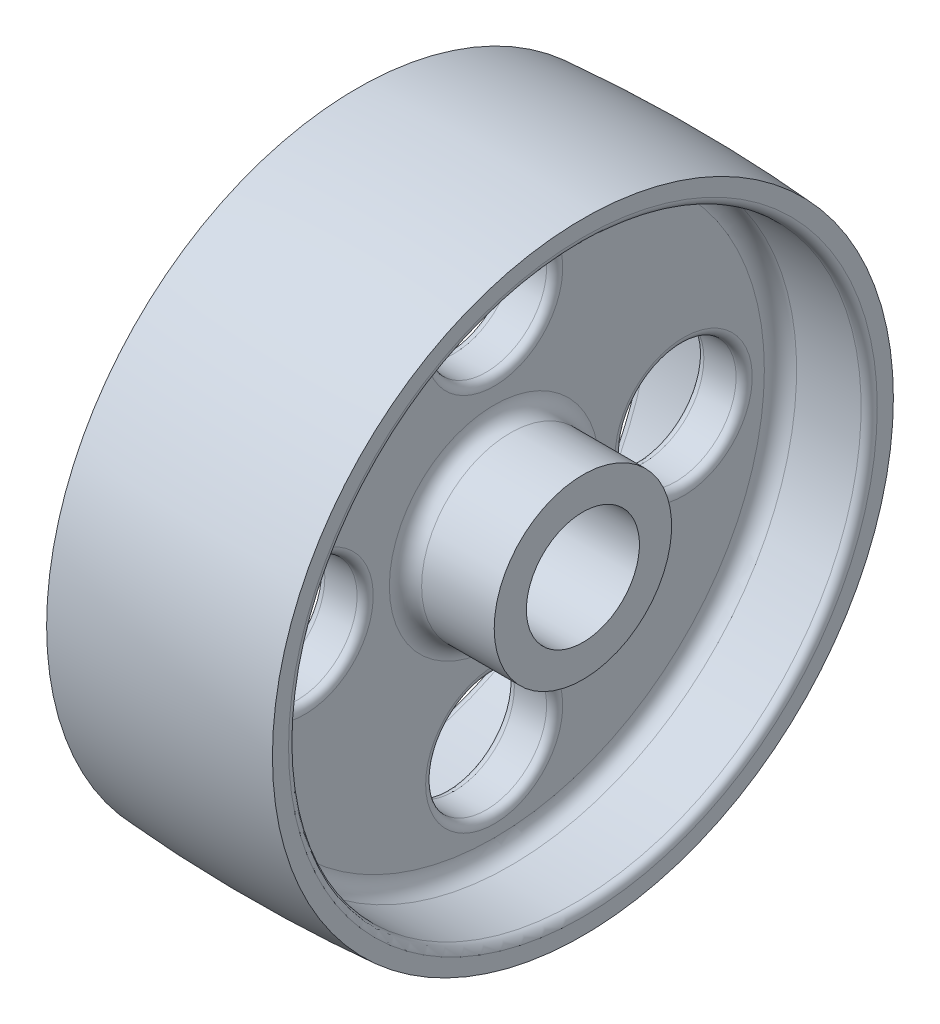
from build123d import *

# Parameters (mm, degrees)
CUT_EXTRUDE2_REACH             = 24.225
SKETCH2_R                      = 11.90625
CUT_EXTRUDE2_DIRECTION_2_REACH = 24.225
FILLET1_R                      = 1.5875


with BuildPart() as part:
    # Sketch1 → Revolve1 (revolve)
    with BuildSketch(Plane.XY):
        with BuildLine():
            Line((22.225, 11.1252), (22.225, 17.4625))
            Line((22.225, 17.4625), (7.9375, 17.4625))
            ThreePointArc((7.9375, 17.4625), (5.69243597, 18.39243597), (4.7625, 20.6375))
            Line((4.7625, 20.6375), (4.7625, 53.18125))
            ThreePointArc((4.7625, 53.18125), (5.69243597, 55.42631403), (7.9375, 56.35625))
            Line((7.9375, 56.35625), (20.6375, 56.35625))
            ThreePointArc((20.6375, 56.35625), (21.760032015, 56.821217985), (22.225, 57.94375))
            Line((22.225, 57.94375), (22.225, 61.11875))
            ThreePointArc((22.225, 61.11875), (0, 61.9125), (-22.225, 61.11875))
            Line((-22.225, 61.11875), (-22.225, 57.94375))
            ThreePointArc((-22.225, 57.94375), (-21.760032015, 56.821217985), (-20.6375, 56.35625))
            Line((-20.6375, 56.35625), (-7.9375, 56.35625))
            ThreePointArc((-7.9375, 56.35625), (-5.69243597, 55.42631403), (-4.7625, 53.18125))
            Line((-4.7625, 53.18125), (-4.7625, 20.6375))
            ThreePointArc((-4.7625, 20.6375), (-5.69243597, 18.39243597), (-7.9375, 17.4625))
            Line((-7.9375, 17.4625), (-22.225, 17.4625))
            Line((-22.225, 17.4625), (-22.225, 11.1252))
            Line((-22.225, 11.1252), (22.225, 11.1252))
        make_face()
    revolve(axis=Axis((0, 0, 0), (1, 0, 0)))

    # Sketch2 → Cut-Extrude2 (cut, up to next)
    with BuildSketch(Plane(origin=(0, 0, 0), x_dir=(0, 0, -1), z_dir=(1, 0, 0)), mode=Mode.PRIVATE) as cut_extrude2_sk1:
        with Locations((0, 37.30625)):
            Circle(SKETCH2_R)
    cut_extrude2_tool1 = extrude(cut_extrude2_sk1.sketch, amount=-CUT_EXTRUDE2_REACH, mode=Mode.PRIVATE) & part.part
    add(cut_extrude2_tool1.solids().sort_by_distance((0, 37.30625, 0))[0], mode=Mode.SUBTRACT)
    # Sketch2 → Cut-Extrude2 (cut, up to next)
    with BuildSketch(Plane(origin=(0, 0, 0), x_dir=(0, 0, -1), z_dir=(1, 0, 0)), mode=Mode.PRIVATE) as cut_extrude2_sk2:
        with Locations((37.30625, 0)):
            Circle(SKETCH2_R)
    cut_extrude2_tool2 = extrude(cut_extrude2_sk2.sketch, amount=-CUT_EXTRUDE2_REACH, mode=Mode.PRIVATE) & part.part
    add(cut_extrude2_tool2.solids().sort_by_distance((0, 0, -37.30625))[0], mode=Mode.SUBTRACT)
    # Sketch2 → Cut-Extrude2 (cut, up to next)
    with BuildSketch(Plane(origin=(0, 0, 0), x_dir=(0, 0, -1), z_dir=(1, 0, 0)), mode=Mode.PRIVATE) as cut_extrude2_sk3:
        with Locations((0, -37.30625)):
            Circle(SKETCH2_R)
    cut_extrude2_tool3 = extrude(cut_extrude2_sk3.sketch, amount=-CUT_EXTRUDE2_REACH, mode=Mode.PRIVATE) & part.part
    add(cut_extrude2_tool3.solids().sort_by_distance((0, -37.30625, 0))[0], mode=Mode.SUBTRACT)
    # Sketch2 → Cut-Extrude2 (cut, up to next)
    with BuildSketch(Plane(origin=(0, 0, 0), x_dir=(0, 0, -1), z_dir=(1, 0, 0)), mode=Mode.PRIVATE) as cut_extrude2_sk4:
        with Locations((-37.30625, 0)):
            Circle(SKETCH2_R)
    cut_extrude2_tool4 = extrude(cut_extrude2_sk4.sketch, amount=-CUT_EXTRUDE2_REACH, mode=Mode.PRIVATE) & part.part
    add(cut_extrude2_tool4.solids().sort_by_distance((0, 0, 37.30625))[0], mode=Mode.SUBTRACT)

    # Sketch2 → Cut-Extrude2 direction 2 (cut, up to next)
    with BuildSketch(Plane(origin=(0, 0, 0), x_dir=(0, 0, -1), z_dir=(1, 0, 0)), mode=Mode.PRIVATE) as cut_extrude2_direction_2_sk1:
        with Locations((0, 37.30625)):
            Circle(SKETCH2_R)
    cut_extrude2_direction_2_tool1 = extrude(cut_extrude2_direction_2_sk1.sketch, amount=CUT_EXTRUDE2_DIRECTION_2_REACH, mode=Mode.PRIVATE) & part.part
    add(cut_extrude2_direction_2_tool1.solids().sort_by_distance((0, 37.30625, 0))[0], mode=Mode.SUBTRACT)
    # Sketch2 → Cut-Extrude2 direction 2 (cut, up to next)
    with BuildSketch(Plane(origin=(0, 0, 0), x_dir=(0, 0, -1), z_dir=(1, 0, 0)), mode=Mode.PRIVATE) as cut_extrude2_direction_2_sk2:
        with Locations((37.30625, 0)):
            Circle(SKETCH2_R)
    cut_extrude2_direction_2_tool2 = extrude(cut_extrude2_direction_2_sk2.sketch, amount=CUT_EXTRUDE2_DIRECTION_2_REACH, mode=Mode.PRIVATE) & part.part
    add(cut_extrude2_direction_2_tool2.solids().sort_by_distance((0, 0, -37.30625))[0], mode=Mode.SUBTRACT)
    # Sketch2 → Cut-Extrude2 direction 2 (cut, up to next)
    with BuildSketch(Plane(origin=(0, 0, 0), x_dir=(0, 0, -1), z_dir=(1, 0, 0)), mode=Mode.PRIVATE) as cut_extrude2_direction_2_sk3:
        with Locations((0, -37.30625)):
            Circle(SKETCH2_R)
    cut_extrude2_direction_2_tool3 = extrude(cut_extrude2_direction_2_sk3.sketch, amount=CUT_EXTRUDE2_DIRECTION_2_REACH, mode=Mode.PRIVATE) & part.part
    add(cut_extrude2_direction_2_tool3.solids().sort_by_distance((0, -37.30625, 0))[0], mode=Mode.SUBTRACT)
    # Sketch2 → Cut-Extrude2 direction 2 (cut, up to next)
    with BuildSketch(Plane(origin=(0, 0, 0), x_dir=(0, 0, -1), z_dir=(1, 0, 0)), mode=Mode.PRIVATE) as cut_extrude2_direction_2_sk4:
        with Locations((-37.30625, 0)):
            Circle(SKETCH2_R)
    cut_extrude2_direction_2_tool4 = extrude(cut_extrude2_direction_2_sk4.sketch, amount=CUT_EXTRUDE2_DIRECTION_2_REACH, mode=Mode.PRIVATE) & part.part
    add(cut_extrude2_direction_2_tool4.solids().sort_by_distance((0, 0, 37.30625))[0], mode=Mode.SUBTRACT)

    # Fillet1
    fillet1_edges = [part.edges().sort_by_distance(p)[0] for p in [
        (4.7625, -37.30625, 11.90625),
        (-4.7625, -37.30625, 11.90625),
        (4.7625, 0, -25.4),
        (-4.7625, 0, -25.4),
        (4.7625, 37.30625, 11.90625),
        (-4.7625, 37.30625, 11.90625),
        (4.7625, 0, 49.2125),
        (-4.7625, 0, 49.2125),
    ]]
    fillet(fillet1_edges, radius=FILLET1_R)


solid = part.part
